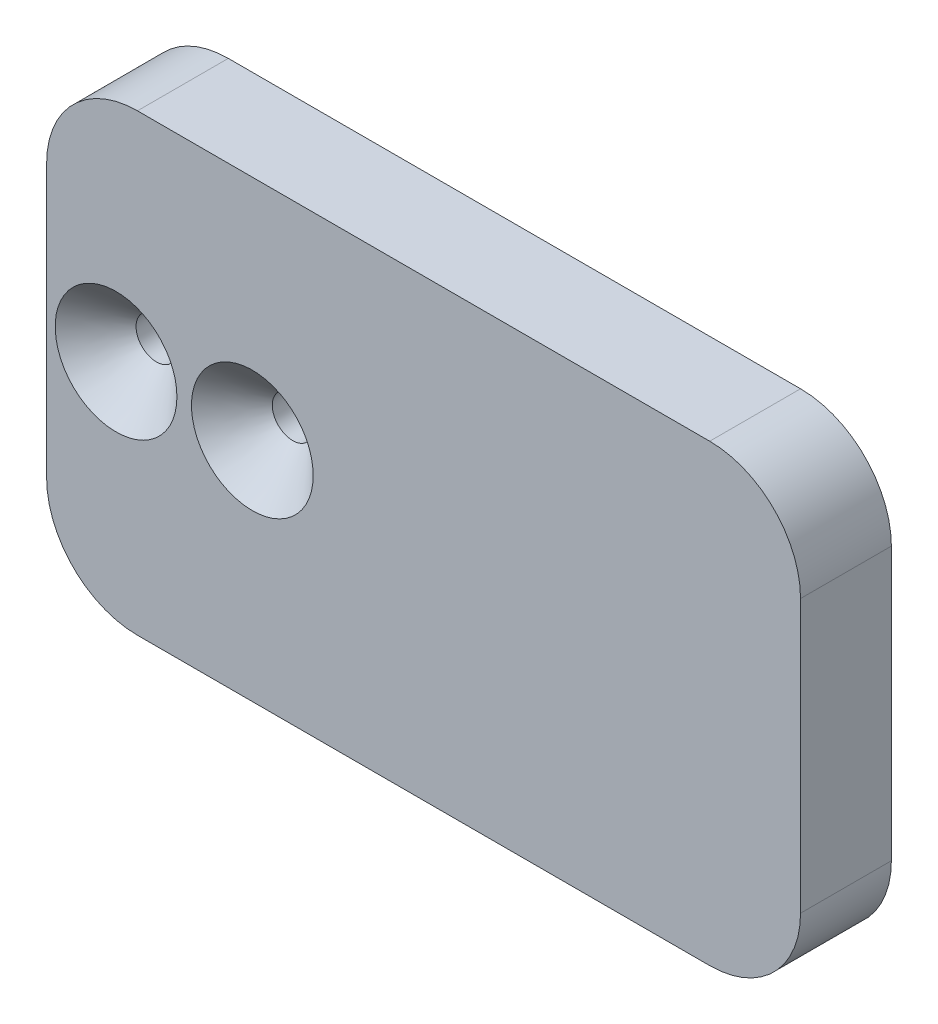
from build123d import *

# Parameters (mm, degrees)
SKETCH2_W                                       = 30
SKETCH2_H                                       = 20
BOSS_EXTRUDE1_DEPTH                             = 25
SKETCH3_W                                       = 83
SKETCH3_H                                       = 50
BOSS_EXTRUDE2_DEPTH                             = 10
CSK_FOR_M4_FLAT_HEAD_MACHINE_SCREW1_D           = 4.5
CSK_FOR_M4_FLAT_HEAD_MACHINE_SCREW1_CSINK_D     = 13.4
CSK_FOR_M4_FLAT_HEAD_MACHINE_SCREW1_CSINK_ANGLE = 90
FILLET1_R                                       = 10
FILLET2_R                                       = 10
FILLET3_R                                       = 3


with BuildPart() as part:
    # Sketch2 → Boss-Extrude1 (new body)
    with BuildSketch(Plane.XY):
        with Locations((-28.360190379, 6.518738069)):
            Rectangle(SKETCH2_W, SKETCH2_H)
    extrude(amount=BOSS_EXTRUDE1_DEPTH)

    # Sketch3 → Boss-Extrude2 (add)
    with BuildSketch(Plane.XY.offset(25)):
        with Locations((-1.860190379, 6.518738069)):
            Rectangle(SKETCH3_W, SKETCH3_H)
    extrude(amount=-BOSS_EXTRUDE2_DEPTH)

    # CSK for M4 Flat Head Machine Screw1 (through all)
    with Locations(Plane.XY.offset(25)):
        with Locations((-35.714941389, 6.421876295), (-20.714941389, 6.421876295)):
            CounterSinkHole(CSK_FOR_M4_FLAT_HEAD_MACHINE_SCREW1_D / 2, CSK_FOR_M4_FLAT_HEAD_MACHINE_SCREW1_CSINK_D / 2, counter_sink_angle=CSK_FOR_M4_FLAT_HEAD_MACHINE_SCREW1_CSINK_ANGLE)

    # Fillet1
    fillet1_edges = [part.edges().sort_by_distance(p)[0] for p in [
        (-43.360190379, -18.481261931, 20),
        (-43.360190379, 31.518738069, 20),
        (39.639809621, 31.518738069, 20),
        (39.639809621, -18.481261931, 20),
    ]]
    fillet(fillet1_edges, radius=FILLET1_R)

    # Fillet2
    fillet2_edges = [part.edges().sort_by_distance(p)[0] for p in [
        (-28.360190379, -3.481261931, 15),
        (-13.360190379, 6.518738069, 15),
        (-28.360190379, 16.518738069, 15),
    ]]
    fillet(fillet2_edges, radius=FILLET2_R)

    # Fillet3
    fillet3_edges = [part.edges().sort_by_distance(p)[0] for p in [
        (-28.360190379, -3.481261931, 0),
        (-13.360190379, 6.518738069, 0),
        (-28.360190379, 16.518738069, 0),
        (-43.360190379, 6.518738069, 0),
    ]]
    fillet(fillet3_edges, radius=FILLET3_R)


solid = part.part
